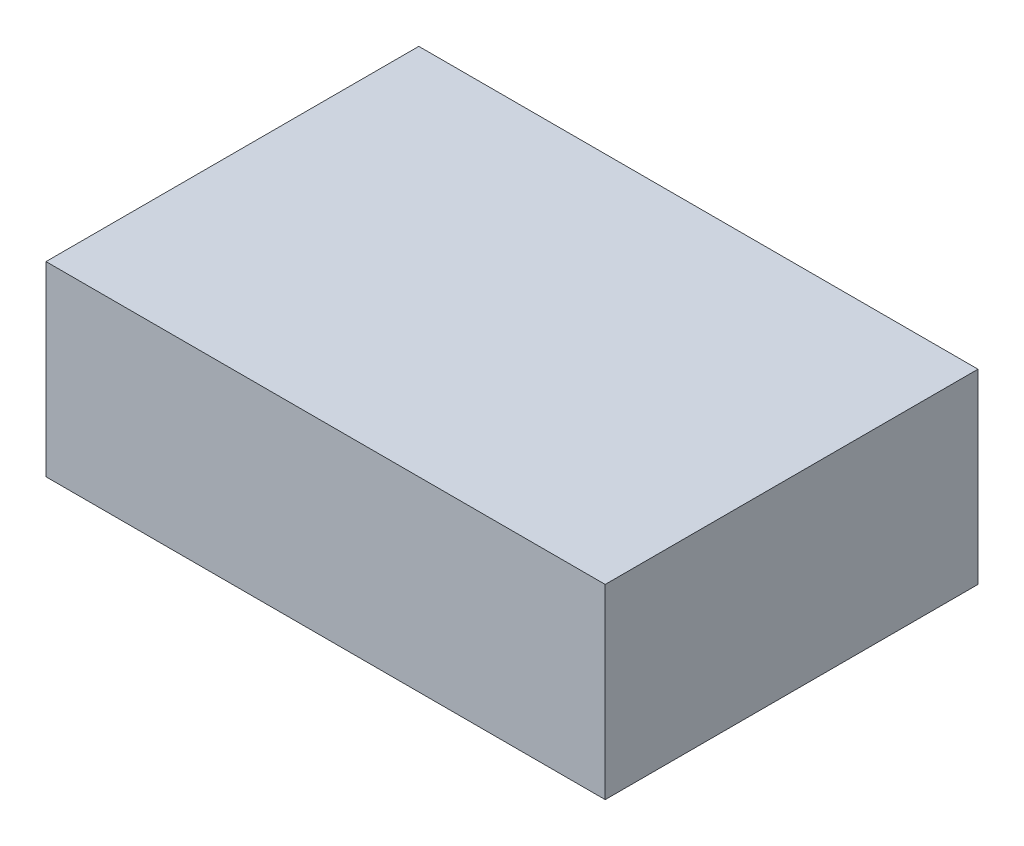
from build123d import *

# Parameters (mm, degrees)
SKETCH2_W           = 152.4
SKETCH2_H           = 101.6
BOSS_EXTRUDE1_DEPTH = 25.4


with BuildPart() as part:
    # Sketch2 → Boss-Extrude1 (new body, symmetric)
    with BuildSketch(Plane(origin=(0, 0, 0), x_dir=(1, 0, 0), z_dir=(0, 1, 0))):
        Rectangle(SKETCH2_W, SKETCH2_H)
    extrude(amount=BOSS_EXTRUDE1_DEPTH, both=True)


solid = part.part
